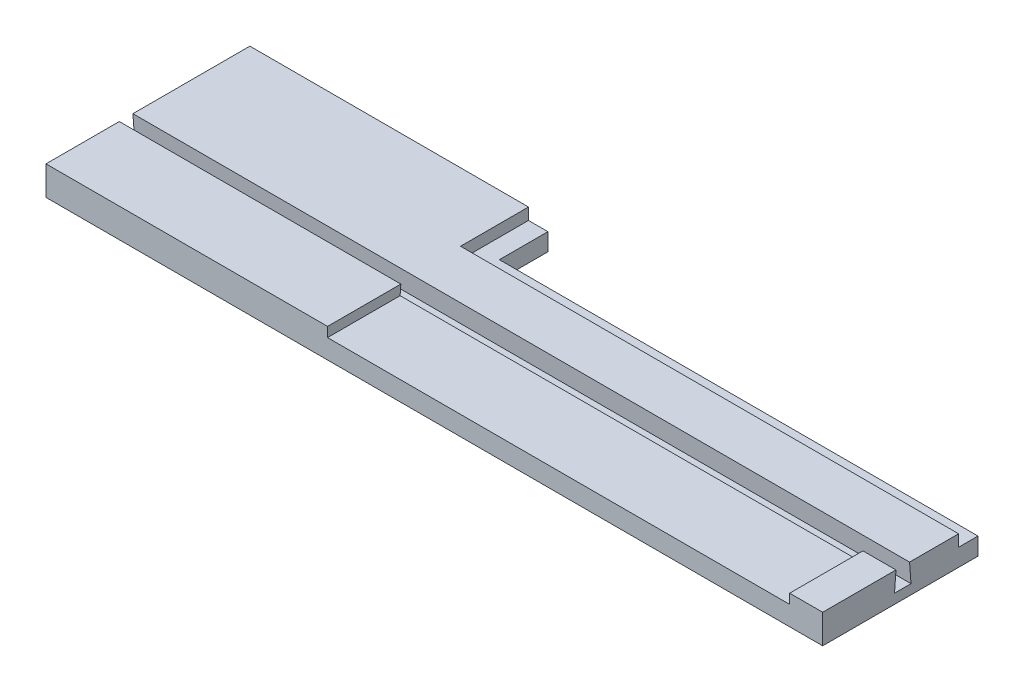
from build123d import *

# Parameters (mm, degrees)
SKETCH1_W           = 80
SKETCH1_H           = 14
BOSS_EXTRUDE1_DEPTH = 2
SKETCH2_W           = 80
SKETCH2_H           = 7.4
SKETCH2_H_2         = 4.9
BOSS_EXTRUDE2_DEPTH = 2
SKETCH3_W           = 28.7
SKETCH3_H           = 7
BOSS_EXTRUDE3_DEPTH = 4
BOSS_EXTRUDE4_DEPTH = 80
CUT_EXTRUDE1_DEPTH  = 1
BOSS_EXTRUDE5_DEPTH = 1.8
SKETCH7_W           = 47.6
SKETCH7_H           = 7.55
CUT_EXTRUDE2_DEPTH  = 1


with BuildPart() as part:
    # Sketch1 → Boss-Extrude1 (new body)
    with BuildSketch(Plane(origin=(0, 0, 0), x_dir=(1, 0, 0), z_dir=(0, 1, 0))):
        with Locations((32.454545455, 2.136363636)):
            Rectangle(SKETCH1_W, SKETCH1_H)
    extrude(amount=BOSS_EXTRUDE1_DEPTH)

    # Sketch2 → Boss-Extrude2 (add)
    with BuildSketch(Plane(origin=(0, 2, 0), x_dir=(1, 0, 0), z_dir=(0, 1, 0))):
        with Locations((32.454545455, -1.163636364)):
            Rectangle(SKETCH2_W, SKETCH2_H)
        with Locations((32.454545455, 6.686363636)):
            Rectangle(SKETCH2_W, SKETCH2_H_2)
    extrude(amount=BOSS_EXTRUDE2_DEPTH)

    # Sketch3 → Boss-Extrude3 (add)
    with BuildSketch(Plane.XZ):
        with Locations((6.804545455, -12.636363636)):
            Rectangle(SKETCH3_W, SKETCH3_H)
    extrude(amount=-BOSS_EXTRUDE3_DEPTH)

    # Sketch4 → Boss-Extrude4 (add)
    with BuildSketch(Plane.ZY.offset(7.545454545)):
        Polygon((-2.536363636, 2), (-2.686363636, 4), (-2.536363636, 4), align=None)
        Polygon((-4.236363636, 2), (-4.236363636, 4), (-4.086363636, 4), align=None)
    extrude(amount=-BOSS_EXTRUDE4_DEPTH)

    # Sketch5 → Cut-Extrude1 (cut)
    with BuildSketch(Plane.XZ):
        Polygon((-7.545454545, 4.863636364), (72.454545455, 4.863636364), (72.454545455, -9.136363636), (21.154545455, -9.136363636), (21.154545455, -16.136363636), (-7.545454545, -16.136363636), align=None)
    extrude(amount=-CUT_EXTRUDE1_DEPTH, mode=Mode.SUBTRACT)

    # Sketch6 → Boss-Extrude5 (add)
    with BuildSketch(Plane.XZ.offset(-1)):
        Polygon((21.154545455, -9.136363636), (72.454545455, -9.136363636), (72.454545455, -11.136363636), (23.154545455, -11.136363636), (23.154545455, -16.136363636), (21.154545455, -16.136363636), (21.154545455, -11.136363636), align=None)
    extrude(amount=-BOSS_EXTRUDE5_DEPTH)

    # Sketch7 → Cut-Extrude2 (cut)
    with BuildSketch(Plane(origin=(0, 4, 0), x_dir=(1, 0, 0), z_dir=(0, 1, 0))):
        with Locations((45.254545455, -1.088636364)):
            Rectangle(SKETCH7_W, SKETCH7_H)
    extrude(amount=-CUT_EXTRUDE2_DEPTH, mode=Mode.SUBTRACT)


solid = part.part
